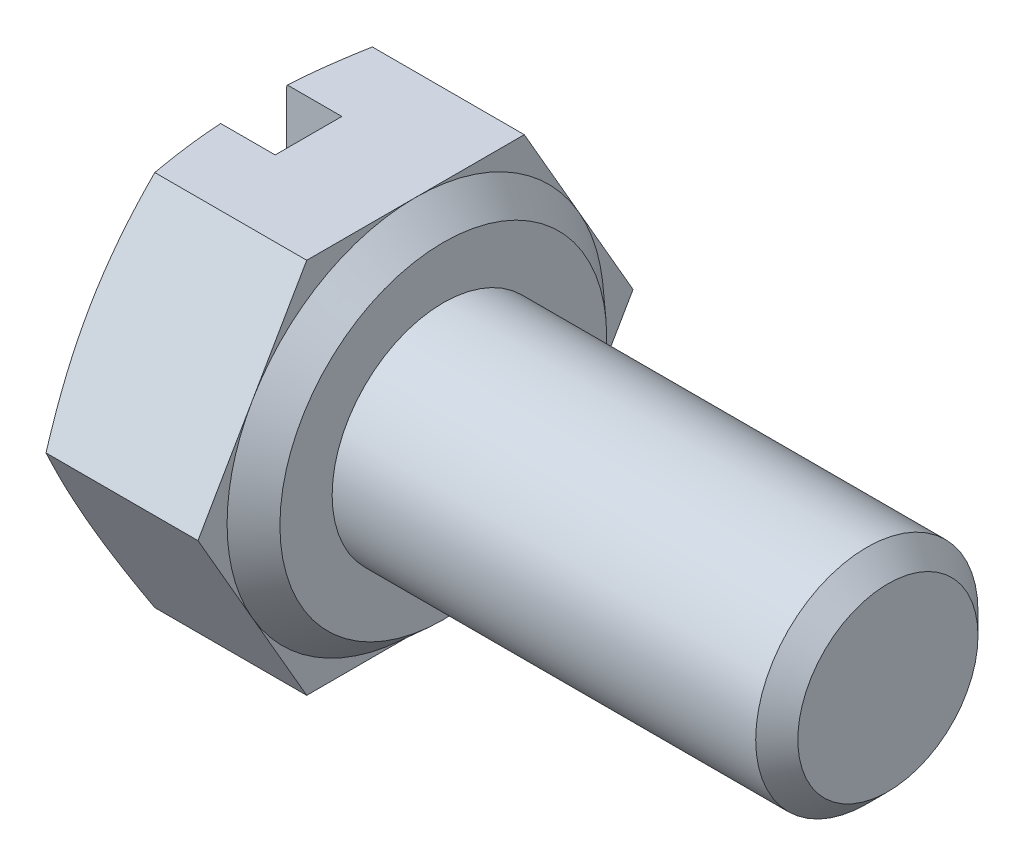
from build123d import *

# Parameters (mm, degrees)
BASEHEAD_DEPTH  = 2.925
SKETCH3_R       = 2
BASEBODY_DEPTH  = 8
CHAMFER1_SIZE   = 0.379
SKETCH5_W       = 1
SKETCH5_H       = 1.2
SLOT_DEPTH      = 4.39
SLOT_DEPTH_BACK = 4.39


with BuildPart() as part:
    # Sketch-BaseHead → BaseHead (new body)
    with BuildSketch(Plane(origin=(0, 0, 0), x_dir=(0, 0, -1), z_dir=(1, 0, 0))):
        Polygon((1.957217413, -3.39), (3.914434825, 0), (1.957217413, 3.39), (-1.957217413, 3.39), (-3.914434825, 0), (-1.957217413, -3.39), align=None)
    extrude(amount=BASEHEAD_DEPTH)

    # Sketch1 → Revolve1 (revolve)
    with BuildSketch(Plane.XY):
        Polygon((2.925, 0), (3.425, 0), (3.425, -2.94), (2.925, -3.39), align=None)
    revolve(axis=Axis((-4.001564945, 0, 0), (1, 0, 0)))

    # Sketch3 → BaseBody (add)
    with BuildSketch(Plane(origin=(3.425, 0, 0), x_dir=(0, 0, -1), z_dir=(1, 0, 0))):
        Circle(SKETCH3_R)
    extrude(amount=BASEBODY_DEPTH)

    # Chamfer1
    chamfer1_edges = [part.edges().sort_by_distance(p)[0] for p in [
        (11.425, 0, 2),
    ]]
    chamfer(chamfer1_edges, length=CHAMFER1_SIZE)

    # Sketch4 → HeadChamfer (revolve, cut)
    with BuildSketch(Plane(origin=(-0.264637255, 0, 5.916896391), x_dir=(0, 0, -1), z_dir=(0, 1, 0))):
        Polygon((9.831331216, -0.264637255), (9.306896391, -0.264637255), (9.831331216, -0.455515922), align=None)
    revolve(axis=Axis((-4.001564945, 0, 0), (1, 0, 0)), mode=Mode.SUBTRACT)

    # Sketch5 → Slot (cut, two sides)
    with BuildSketch(Plane(origin=(0, 0, 0), x_dir=(1, 0, 0), z_dir=(0, 1, 0))) as slot_sk:
        with Locations((0.5, 0)):
            Rectangle(SKETCH5_W, SKETCH5_H)
    extrude(amount=SLOT_DEPTH, mode=Mode.SUBTRACT)
    extrude(slot_sk.sketch, amount=-SLOT_DEPTH_BACK, mode=Mode.SUBTRACT)


solid = part.part
